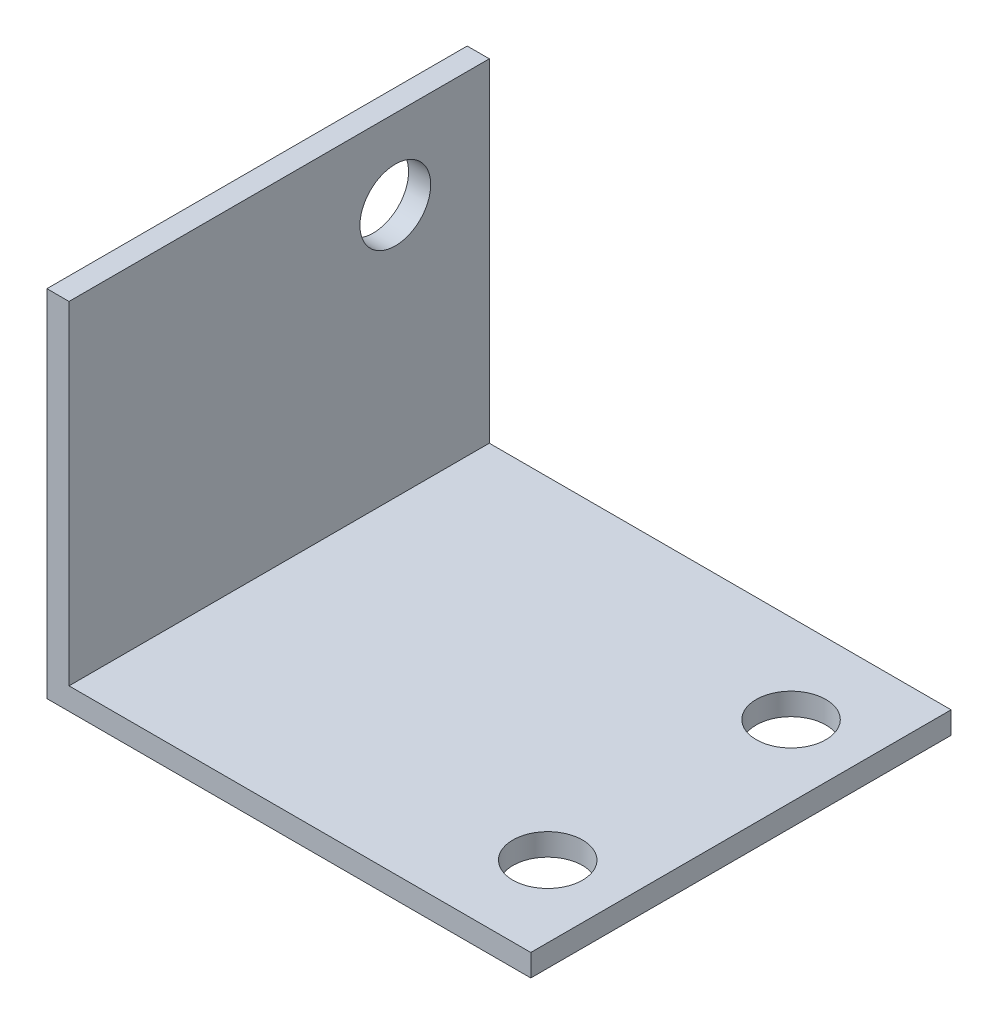
from build123d import *

# Parameters (mm, degrees)
SKETCH1_W  = 43.75
SKETCH1_H  = 38
SKETCH1_R  = 3.15
BASE_DEPTH = 2
SKETCH2_W  = 38
SKETCH2_H  = 32.1
SKETCH2_R  = 3.2
TAB_DEPTH  = 2


with BuildPart() as part:
    # Sketch1 → Base (new body)
    with BuildSketch(Plane(origin=(0, 0, 0), x_dir=(1, 0, 0), z_dir=(0, 1, 0))):
        Rectangle(SKETCH1_W, SKETCH1_H)
        with Locations((15.405, 11)):
            Circle(SKETCH1_R, mode=Mode.SUBTRACT)
        with Locations((15.405, -11)):
            Circle(SKETCH1_R, mode=Mode.SUBTRACT)
    extrude(amount=BASE_DEPTH)

    # Sketch2 → Tab (add)
    with BuildSketch(Plane.ZY.offset(21.875)):
        with Locations((0, 16.05)):
            Rectangle(SKETCH2_W, SKETCH2_H)
        with Locations((-10.5, 24.9)):
            Circle(SKETCH2_R, mode=Mode.SUBTRACT)
    extrude(amount=-TAB_DEPTH)


solid = part.part
